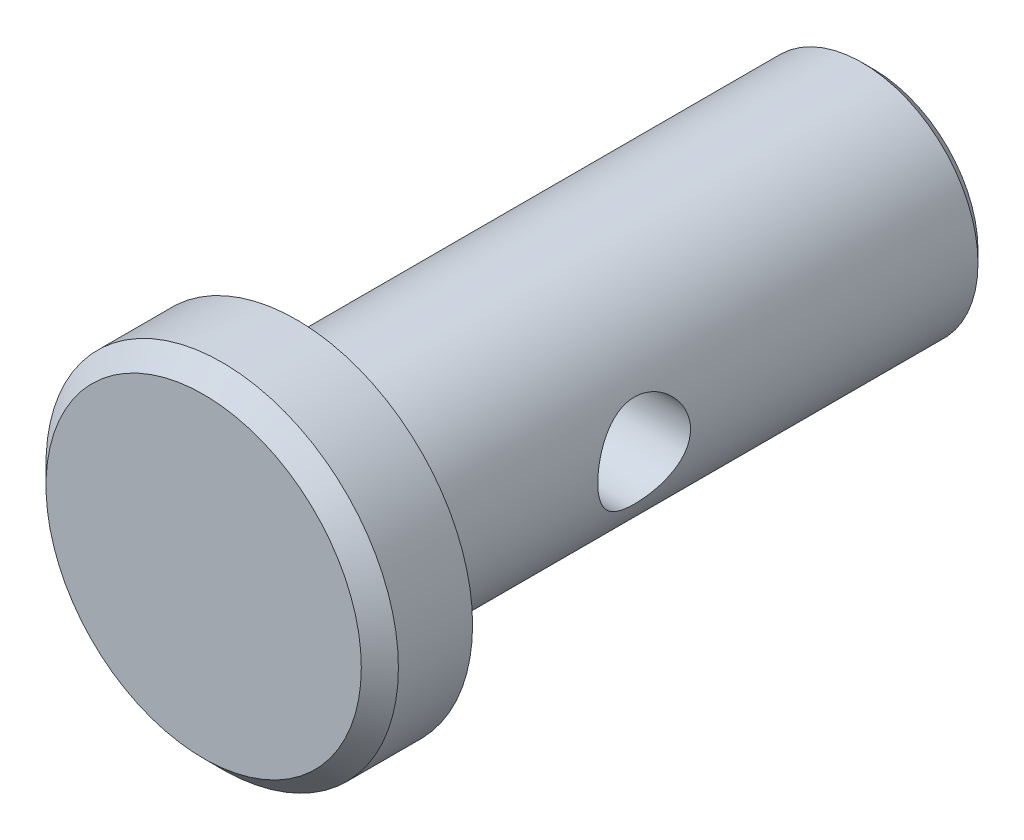
from build123d import *

# Parameters (mm, degrees)
EXTRUDE1_DEPTH          = 14.2875
EXTRUDE1_DEPTH_BACK     = 1.524
SKETCH1_R               = 3.175
SKETCH2_R               = 4.826
EXTRUDE2_DEPTH          = 2.54
CHAMFER1_SIZE           = 0.508
CHAMFER2_SIZE           = 0.3175
CUT_EXTRUDE1_DEPTH      = 3.175
CUT_EXTRUDE1_DEPTH_BACK = 3.175
SKETCH9_R               = 1.27


with BuildPart() as part:
    # Sketch1 → Extrude1 (new, two sides: drawn at the far end of the back side and taken through both)
    with BuildSketch(Plane.XY.offset(-EXTRUDE1_DEPTH_BACK)):
        Circle(SKETCH1_R)
    extrude(amount=EXTRUDE1_DEPTH + EXTRUDE1_DEPTH_BACK)

    # Sketch2 → Extrude2 (add)
    with BuildSketch(Plane.XY.offset(14.2875)):
        Circle(SKETCH2_R)
    extrude(amount=EXTRUDE2_DEPTH)

    # Chamfer1
    chamfer1_edges = [part.edges().sort_by_distance(p)[0] for p in [
        (-4.826, 0, 16.8275),
    ]]
    chamfer(chamfer1_edges, length=CHAMFER1_SIZE)

    # Chamfer2
    chamfer2_edges = [part.edges().sort_by_distance(p)[0] for p in [
        (-3.175, 0, -1.524),
    ]]
    chamfer(chamfer2_edges, length=CHAMFER2_SIZE)

    # Sketch9 → Cut-Extrude1 (cut, two sides: drawn at the far end of the back side and taken through both)
    with BuildSketch(Plane(origin=(0, 0, 0), x_dir=(0, 0, -1), z_dir=(1, 0, 0)).offset(-CUT_EXTRUDE1_DEPTH_BACK)):
        with Locations((-7.9375, 0)):
            Circle(SKETCH9_R)
    extrude(amount=CUT_EXTRUDE1_DEPTH + CUT_EXTRUDE1_DEPTH_BACK, mode=Mode.SUBTRACT)


solid = part.part
